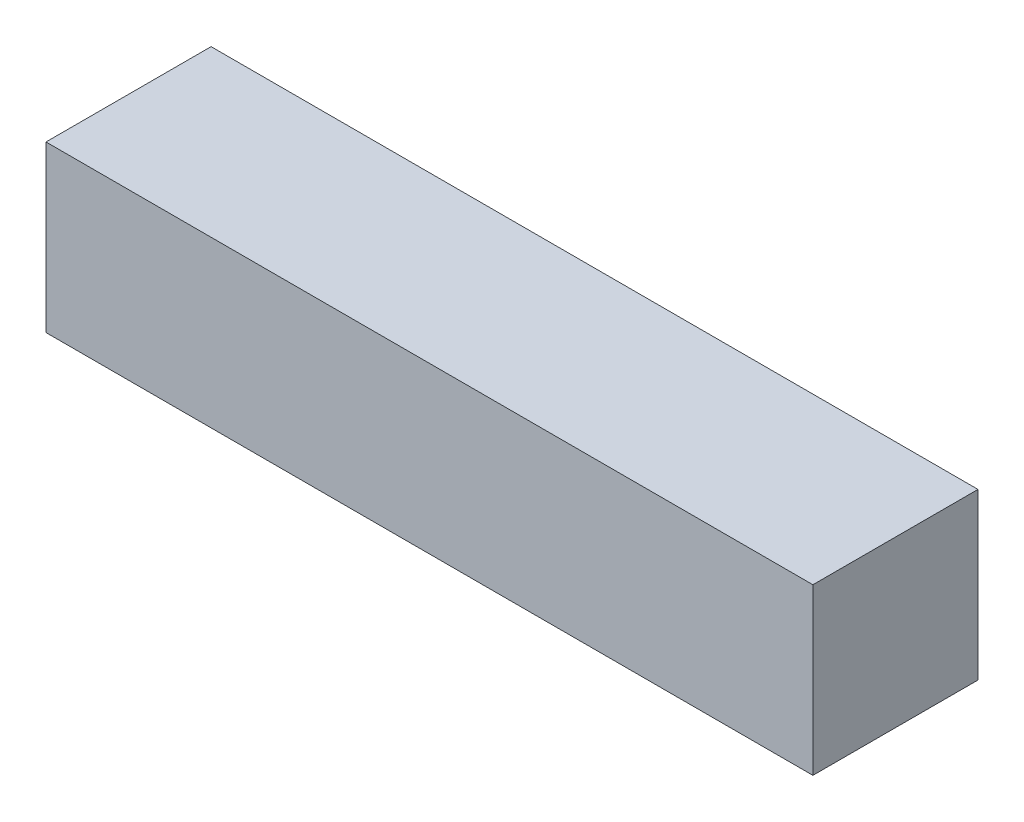
from build123d import *

# Parameters (mm, degrees)
SKETCH1_W           = 3.1
SKETCH1_H           = 3.1
BOSS_EXTRUDE1_DEPTH = 7.2


with BuildPart() as part:
    # Sketch1 → Boss-Extrude1 (new body, symmetric)
    with BuildSketch(Plane(origin=(0, 0, 0), x_dir=(0, 0, -1), z_dir=(1, 0, 0))):
        Rectangle(SKETCH1_W, SKETCH1_H)
    extrude(amount=BOSS_EXTRUDE1_DEPTH, both=True)


solid = part.part
